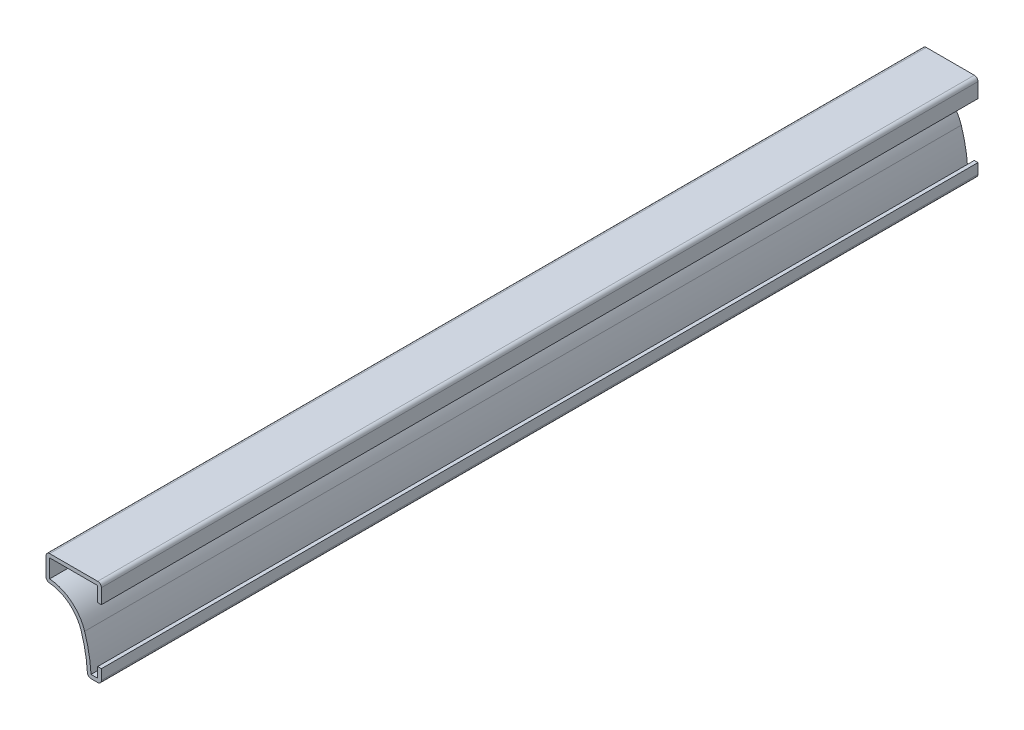
from build123d import *

# Parameters (mm, degrees)
EXTRUDE_THIN1_DEPTH = 301.625
FILLET1_R           = 1.27


with BuildPart() as part:
    # Sketch1 → Extrude-Thin1 (new body)
    with BuildSketch(Plane.XY):
        with BuildLine():
            Line((0, 0), (0, 6.35))
            Line((0, 6.35), (-19.05, 6.35))
            Line((-19.05, 6.35), (-19.05, -2.38125))
            ThreePointArc((-19.05, -2.38125), (-11.575450433, -4.813771791), (-6.964208693, -11.179500588))
            ThreePointArc((-6.964208693, -11.179500588), (-5.421346287, -17.418966095), (-4.7625, -23.8125))
            Line((-4.7625, -23.8125), (0, -23.8125))
            Line((0, -23.8125), (0, -19.05))
            Line((0, -19.05), (-1.27, -19.05))
            Line((-1.27, -19.05), (-1.27, -22.5425))
            Line((-1.27, -22.5425), (-3.549505015, -22.5425))
            ThreePointArc((-3.549505015, -22.5425), (-4.279699966, -16.595923923), (-5.755629562, -10.789325647))
            ThreePointArc((-5.755629562, -10.789325647), (-10.322605132, -4.172836787), (-17.78, -1.169097039))
            Line((-17.78, -1.169097039), (-17.78, 5.08))
            Line((-17.78, 5.08), (-1.27, 5.08))
            Line((-1.27, 5.08), (-1.27, 0))
            Line((-1.27, 0), (0, 0))
        make_face()
    extrude(amount=-EXTRUDE_THIN1_DEPTH)

    # Fillet1
    fillet1_edges = [part.edges().sort_by_distance(p)[0] for p in [
        (0, -23.8125, -150.8125),
        (-4.7625, -23.8125, -150.8125),
        (-19.05, -2.38125, -150.8125),
        (-19.05, 6.35, -150.8125),
        (0, 6.35, -150.8125),
    ]]
    fillet(fillet1_edges, radius=FILLET1_R)


solid = part.part
